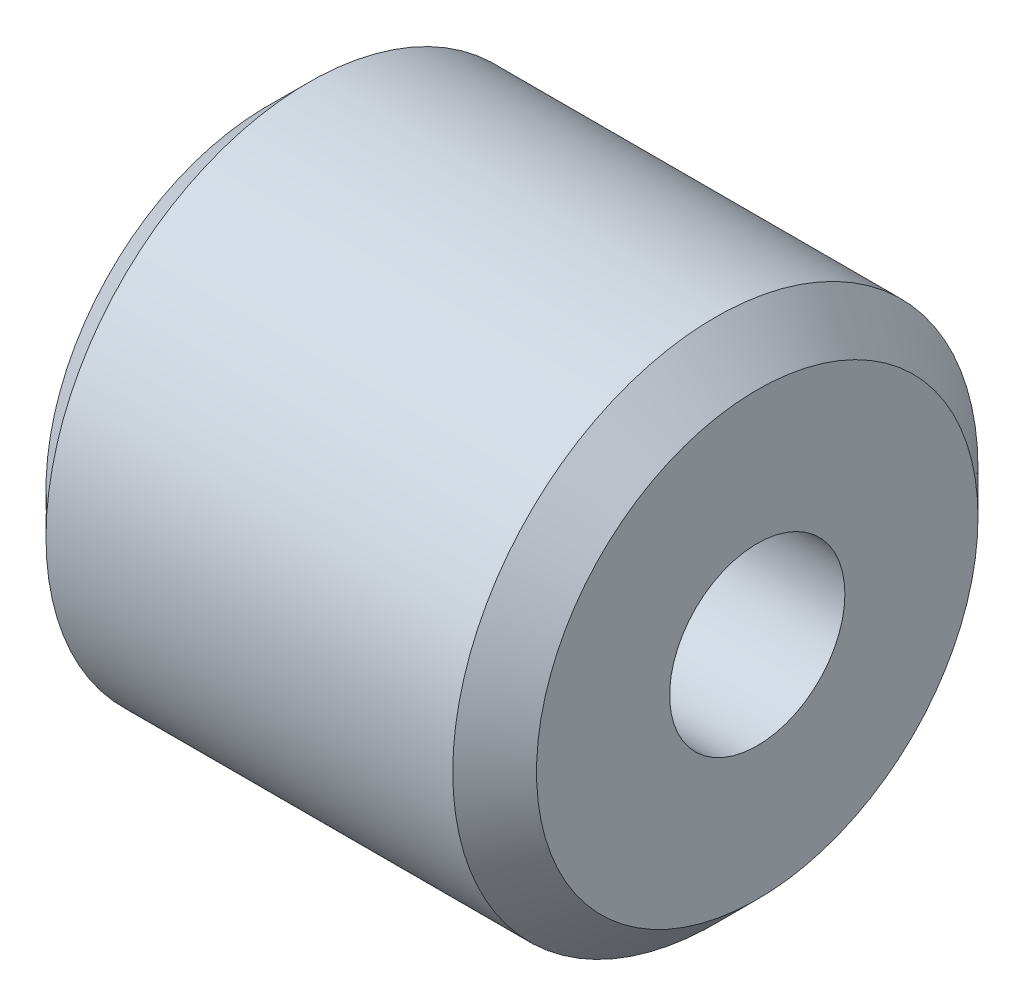
from build123d import *

# Parameters (mm, degrees)
CROQUIS1_R              = 4.765
CROQUIS1_R_2            = 1.59
SALIENTE_EXTRUIR1_DEPTH = 4.45
CHAFL_N1_SIZE           = 0.76


with BuildPart() as part:
    # Croquis1 → Saliente-Extruir1 (new body, symmetric)
    with BuildSketch(Plane(origin=(0, 0, 0), x_dir=(0, 0, -1), z_dir=(1, 0, 0))):
        Circle(CROQUIS1_R)
        Circle(CROQUIS1_R_2, mode=Mode.SUBTRACT)
    extrude(amount=SALIENTE_EXTRUIR1_DEPTH, both=True)

    # Chaflán1
    chafl_n1_edges = [part.edges().sort_by_distance(p)[0] for p in [
        (-4.45, 0, 4.765),
        (4.45, 0, 4.765),
    ]]
    chamfer(chafl_n1_edges, length=CHAFL_N1_SIZE)


solid = part.part
